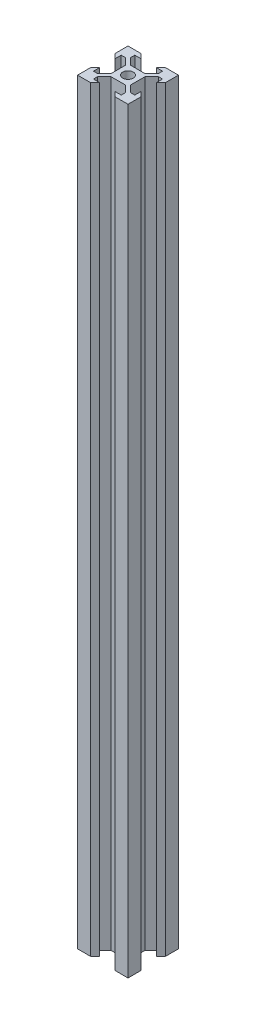
from build123d import *

# Parameters (mm, degrees)
SKETCH_1_R      = 2.1
EXTRUDE_1_DEPTH = 300


with BuildPart() as part:
    # 草图1 → 凸台-拉伸1 (new body)
    with BuildSketch(Plane(origin=(0, 0, 0), x_dir=(1, 0, 0), z_dir=(0, 1, 0))):
        Polygon((-10, 10), (-4.9, 10), (-3.1, 8.2), (-5.5, 8.2), (-5.5, 6.560660172), (-2.839339828, 3.9), (0, 3.9), (2.839339828, 3.9), (5.5, 6.560660172), (5.5, 8.2), (3.1, 8.2), (4.9, 10), (10, 10), (10, 4.9), (8.2, 3.1), (8.2, 5.5), (6.560660172, 5.5), (3.9, 2.839339828), (3.9, -2.839339828), (6.560660172, -5.5), (8.2, -5.5), (8.2, -3.1), (10, -4.9), (10, -10), (4.9, -10), (3.1, -8.2), (5.5, -8.2), (5.5, -6.560660172), (2.839339828, -3.9), (0, -3.9), (-2.839339828, -3.9), (-5.5, -6.560660172), (-5.5, -8.2), (-3.1, -8.2), (-4.9, -10), (-10, -10), (-10, -4.9), (-8.2, -3.1), (-8.2, -5.5), (-6.560660172, -5.5), (-3.9, -2.839339828), (-3.9, 2.839339828), (-6.560660172, 5.5), (-8.2, 5.5), (-8.2, 3.1), (-10, 4.9), align=None)
        Circle(SKETCH_1_R, mode=Mode.SUBTRACT)
    extrude(amount=EXTRUDE_1_DEPTH)


solid = part.part
